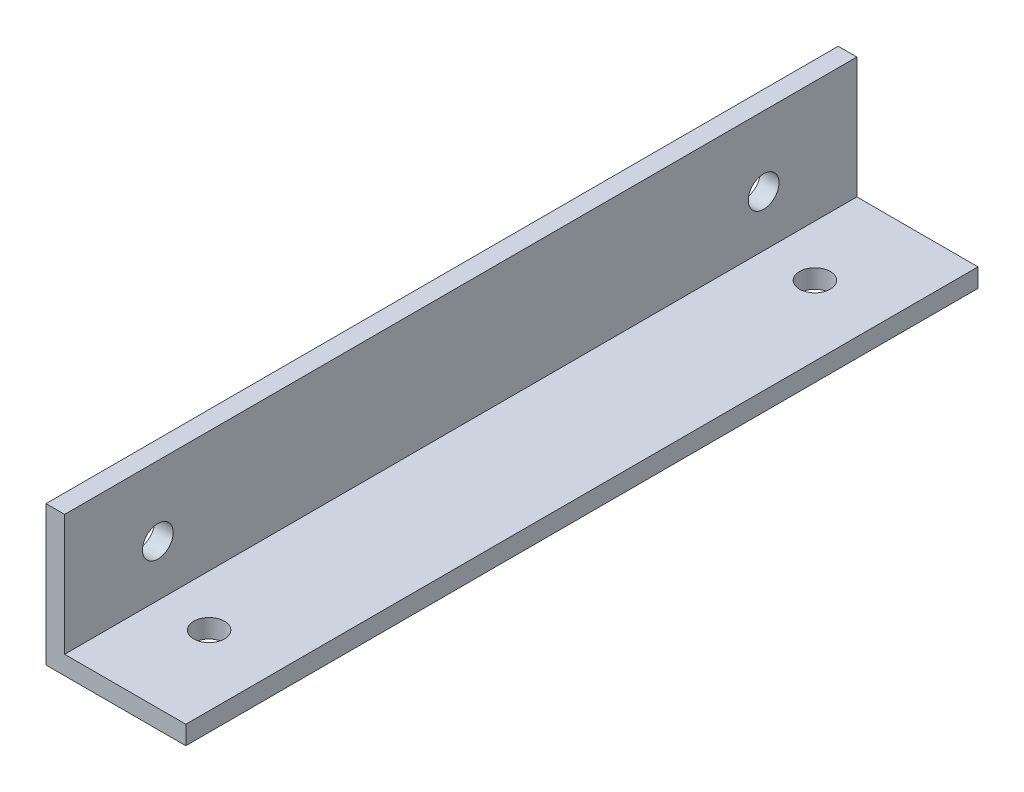
from build123d import *

# Parameters (mm, degrees)
EXTRUDE_1_DEPTH          = 85
M4X0_7_1_D               = 3.3
M4X0_7_1_DEPTH           = 11.5
M4X0_7_1_TIP             = 0.991420021
M4X0_7_1_ON_FACE_2_D     = 3.3
M4X0_7_1_ON_FACE_2_DEPTH = 11.5
M4X0_7_1_ON_FACE_2_TIP   = 0.991420021


with BuildPart() as part:
    # ｽｹｯﾁ1 → ﾎﾞｽ - 押し出し1 (new body)
    with BuildSketch(Plane.XY):
        Polygon((0, 0), (0, 15), (2, 15), (2, 2), (15, 2), (15, 0), align=None)
    extrude(amount=EXTRUDE_1_DEPTH)

    # M4x0.7 ねじ穴1
    with Locations(Plane(origin=(0, 7.5, 75), x_dir=(0, 0, -1), z_dir=(-1, 0, 0))):
        with Locations((0, 0), (65, 0)):
            Hole(M4X0_7_1_D / 2, depth=M4X0_7_1_DEPTH)
            with Locations((0, 0, -(M4X0_7_1_DEPTH + M4X0_7_1_TIP / 2))):  # 118° drill point
                Cone(0, M4X0_7_1_D / 2, M4X0_7_1_TIP, mode=Mode.SUBTRACT)

    # M4x0.7 ねじ穴1 on face 2
    with Locations(Plane(origin=(7.5, 0, 75), x_dir=(0, 0, -1), z_dir=(0, -1, 0))):
        with Locations((0, 0), (65, 0)):
            Hole(M4X0_7_1_ON_FACE_2_D / 2, depth=M4X0_7_1_ON_FACE_2_DEPTH)
            with Locations((0, 0, -(M4X0_7_1_ON_FACE_2_DEPTH + M4X0_7_1_ON_FACE_2_TIP / 2))):  # 118° drill point
                Cone(0, M4X0_7_1_ON_FACE_2_D / 2, M4X0_7_1_ON_FACE_2_TIP, mode=Mode.SUBTRACT)


solid = part.part
